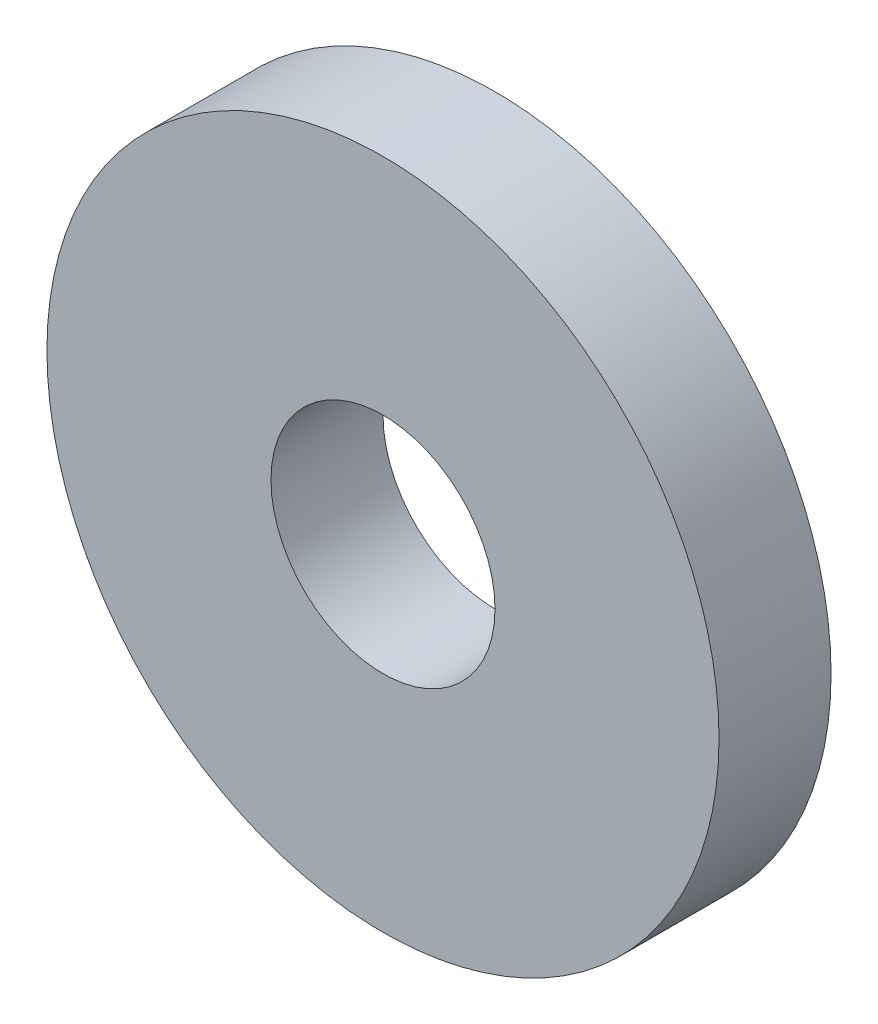
from build123d import *

# Parameters (mm, degrees)
SKETCH1_R           = 15
SKETCH1_R_2         = 5
BOSS_EXTRUDE1_DEPTH = 5


with BuildPart() as part:
    # Sketch1 → Boss-Extrude1 (new body)
    with BuildSketch(Plane.XY):
        Circle(SKETCH1_R)
        Circle(SKETCH1_R_2, mode=Mode.SUBTRACT)
    extrude(amount=BOSS_EXTRUDE1_DEPTH)


solid = part.part
